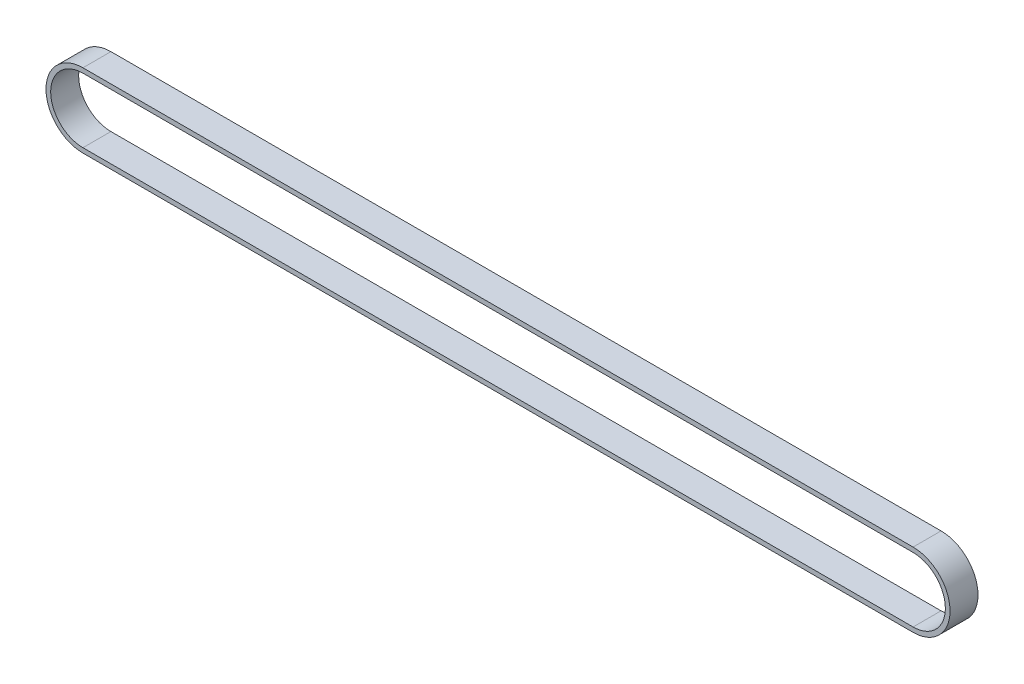
from build123d import *

# Parameters (mm, degrees)
BOSS_EXTRUDE1_DEPTH = 6


with BuildPart() as part:
    # Sketch2 → Boss-Extrude1 (new body)
    with BuildSketch(Plane.XY):
        with BuildLine():
            Line((-89, 1), (89, 1))
            ThreePointArc((89, 1), (96.92, -6.92), (89, -14.84))
            Line((89, -14.84), (-89, -14.84))
            ThreePointArc((-89, -14.84), (-96.92, -6.92), (-89, 1))
        make_face()
        with BuildLine():
            Line((-89, 0), (89, 0))
            ThreePointArc((89, 0), (95.92, -6.92), (89, -13.84))
            Line((89, -13.84), (-89, -13.84))
            ThreePointArc((-89, -13.84), (-95.92, -6.92), (-89, 0))
        make_face(mode=Mode.SUBTRACT)
    extrude(amount=BOSS_EXTRUDE1_DEPTH)


solid = part.part
